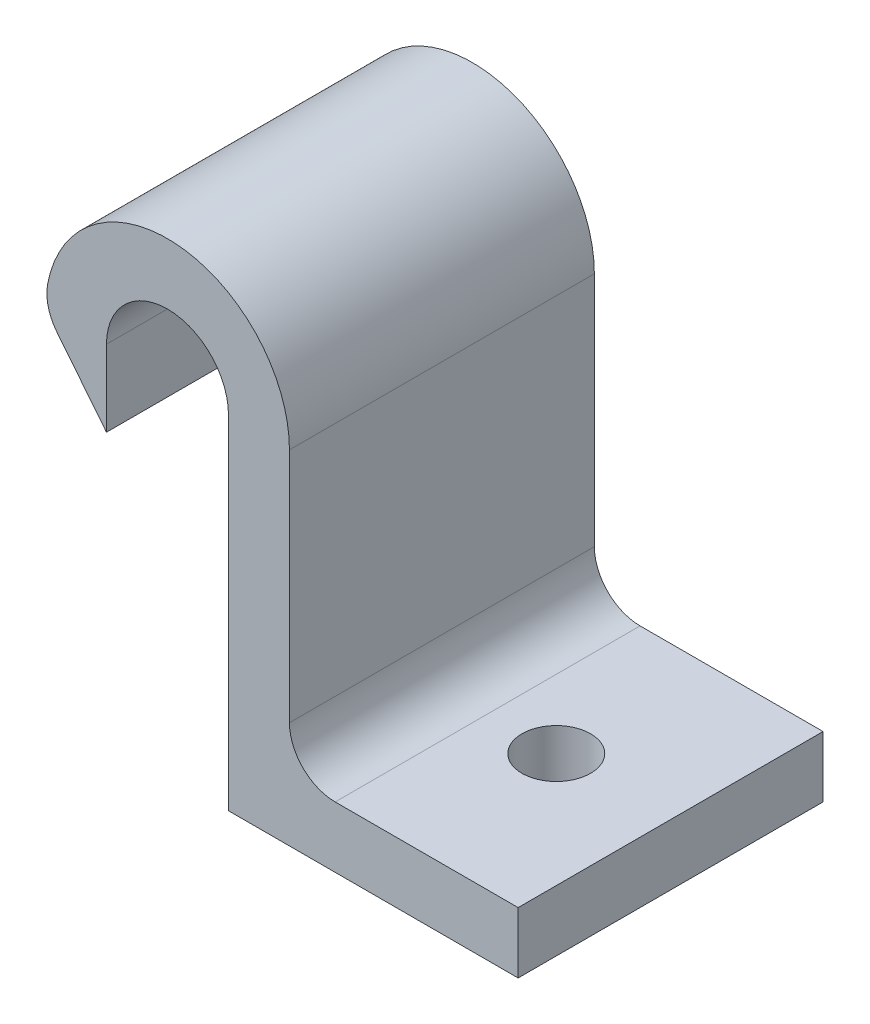
from build123d import *

# Parameters (mm, degrees)
SALIENTE_EXTRUIR1_DEPTH = 20
CROQUIS2_R              = 2.25
CORTAR_EXTRUIR1_DEPTH   = 4
REDONDEO1_R             = 3


with BuildPart() as part:
    # Croquis1 → Saliente-Extruir1 (new body)
    with BuildSketch(Plane.XY):
        with BuildLine():
            Line((0, 0), (0, 22.5))
            ThreePointArc((0, 22.5), (-4, 26.5), (-8, 22.5))
            Line((-8, 22.5), (-8, 17.5))
            Line((-8, 17.5), (-12, 22.5))
            ThreePointArc((-12, 22.5), (-4, 30.5), (4, 22.5))
            Line((4, 22.5), (4, 4))
            Line((4, 4), (19, 4))
            Line((19, 4), (19, 0))
            Line((19, 0), (0, 0))
        make_face()
    extrude(amount=SALIENTE_EXTRUIR1_DEPTH)

    # Croquis2 → Cortar-Extruir1 (cut)
    with BuildSketch(Plane(origin=(0, 4, 0), x_dir=(1, 0, 0), z_dir=(0, 1, 0))):
        with Locations((11.5, -10)):
            Circle(CROQUIS2_R)
    extrude(amount=-CORTAR_EXTRUIR1_DEPTH, mode=Mode.SUBTRACT)

    # Redondeo1
    redondeo1_edges = [part.edges().sort_by_distance(p)[0] for p in [
        (-12, 22.5, 10),
        (4, 4, 10),
    ]]
    fillet(redondeo1_edges, radius=REDONDEO1_R)


solid = part.part
